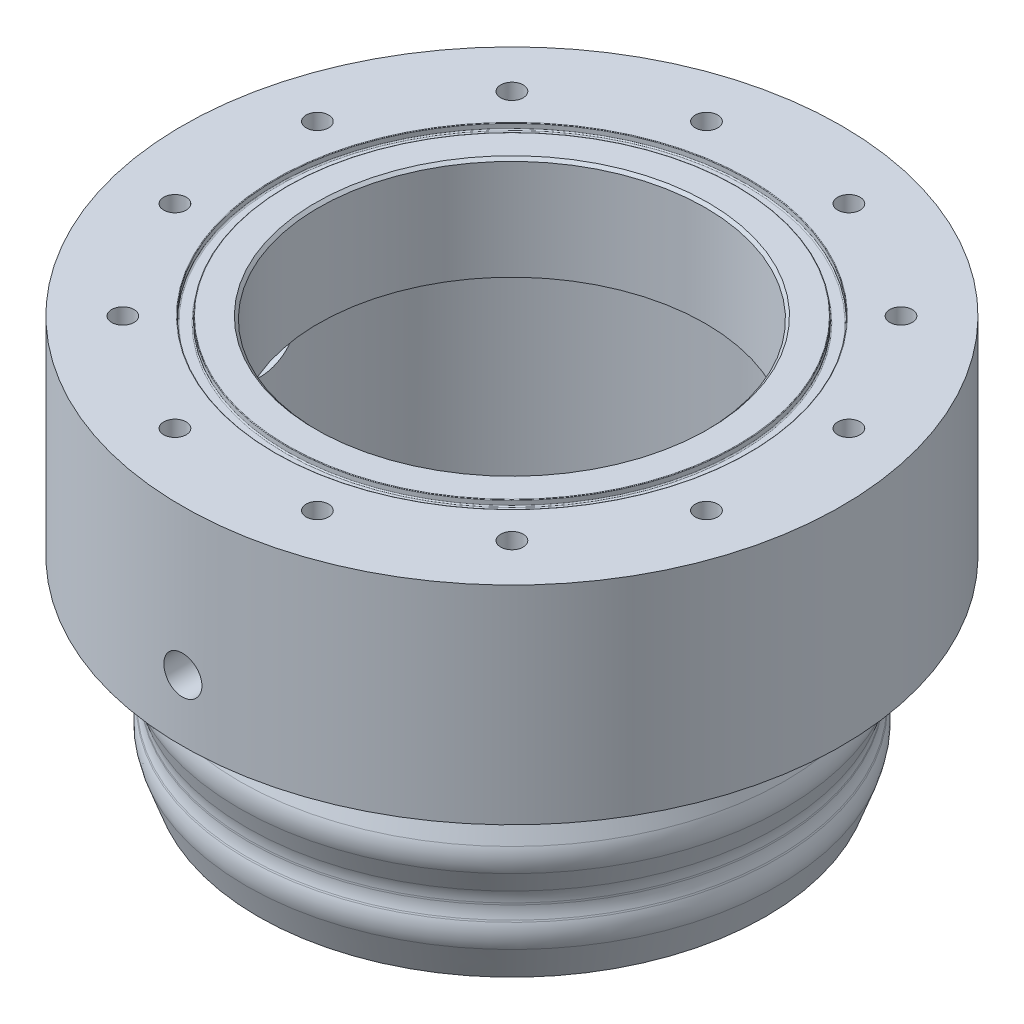
from build123d import *

# Parameters (mm, degrees)
ASSEMBLY_BOLT_INSERT_DIAMETER_R = 2.4892
ASSEMBLY_BOLT_INSERT_CUT_DEPTH  = 21.59
ASSEMBLY_BOLTS_COUNT            = 12
PT_CUT_DIAMETER_R               = 4.2164
PT_CUT_DEPTH                    = 158.465917682
FILLET1_R                       = 7.62
FILLET2_R                       = 2.54
FILLET3_R                       = 7.62
FILLET7_R                       = 7.62
SKETCH24_R                      = 7.14375
CUT_EXTRUDE2_DEPTH              = 25.4
CHAMFER1_SIZE                   = 0.635


with BuildPart() as part:
    # Flange profile → Flange (revolve)
    with BuildSketch(Plane.XY):
        with BuildLine():
            Line((-42.8625, 22.86), (-42.8625, 0))
            Line((-42.8625, 0), (-55.7276, 0))
            Line((-55.7276, 0), (-55.7276, -64.266896465))
            Line((-55.7276, -64.266896465), (-56.2356, -64.266896465))
            Line((-56.2356, -64.266896465), (-59.7916, -54.496866762))
            Line((-59.7916, -54.496866762), (-58.2676, -50.309711174))
            Line((-58.2676, -50.309711174), (-58.2676, -47.236311174))
            Line((-58.2676, -47.236311174), (-61.3156, -38.862))
            Line((-61.3156, -38.862), (-58.2676, -30.487688826))
            Line((-58.2676, -30.487688826), (-58.2676, -23.151254335))
            Line((-58.2676, -23.151254335), (-73.025, -23.151254335))
            Line((-73.025, -23.151254335), (-73.025, 22.86))
            Line((-73.025, 22.86), (-52.5653, 22.86))
            ThreePointArc((-52.5653, 22.86), (-52.475497439, 22.822802561), (-52.4383, 22.733))
            Line((-52.4383, 22.733), (-52.4383, 21.7932))
            ThreePointArc((-52.4383, 21.7932), (-52.363905122, 21.613594878), (-52.1843, 21.5392))
            Line((-52.1843, 21.5392), (-50.1269, 21.5392))
            ThreePointArc((-50.1269, 21.5392), (-49.947294878, 21.613594878), (-49.8729, 21.7932))
            Line((-49.8729, 21.7932), (-49.8729, 22.733))
            ThreePointArc((-49.8729, 22.733), (-49.835702561, 22.822802561), (-49.7459, 22.86))
            Line((-49.7459, 22.86), (-42.8625, 22.86))
        make_face()
    revolve(axis=Axis((0, 0, 0), (0, 1, 0)))

    # Assembly Bolt Insert Diameter → Assembly Bolt Insert Cut (cut)
    with BuildSketch(Plane(origin=(0, 22.86, 0), x_dir=(1, 0, 0), z_dir=(0, 1, 0))):
        with Locations((-58.882838371, 15.777608989)):
            Circle(ASSEMBLY_BOLT_INSERT_DIAMETER_R)
    assembly_bolt_insert_cut = extrude(amount=-ASSEMBLY_BOLT_INSERT_CUT_DEPTH, mode=Mode.SUBTRACT)

    # Assembly Bolts: Assembly Bolt Insert Cut ×12 about axis
    assembly_bolts_axis = Axis((0, 0, 0), (0, -1, 0))
    for i in range(1, ASSEMBLY_BOLTS_COUNT):
        add(assembly_bolt_insert_cut.rotate(assembly_bolts_axis, i * 360 / ASSEMBLY_BOLTS_COUNT), mode=Mode.SUBTRACT)

    # Pt Cut Diameter → Pt Cut (cut, through all)
    with BuildSketch(Plane.XY.offset(50.8)):
        with Locations((0, -9.525)):
            Circle(PT_CUT_DIAMETER_R)
    extrude(amount=PT_CUT_DEPTH, mode=Mode.SUBTRACT)

    # Fillet1
    fillet1_edges = [part.edges().sort_by_distance(p)[0] for p in [
        (61.3156, -38.862, 0),
    ]]
    fillet(fillet1_edges, radius=FILLET1_R)

    # Fillet2
    fillet2_edges = [part.edges().sort_by_distance(p)[0] for p in [
        (58.2676, -23.151254335, 0),
        (55.7276, 0, 0),
    ]]
    fillet(fillet2_edges, radius=FILLET2_R)

    # Fillet3
    fillet3_edges = [part.edges().sort_by_distance(p)[0] for p in [
        (59.7916, -54.496866762, 0),
    ]]
    fillet(fillet3_edges, radius=FILLET3_R)

    # Fillet7
    fillet7_edges = [part.edges().sort_by_distance(p)[0] for p in [
        (58.2676, -50.309711174, 0),
        (58.2676, -47.236311174, 0),
        (58.2676, -30.487688826, 0),
    ]]
    fillet(fillet7_edges, radius=FILLET7_R)

    # Sketch24 → Cut-Extrude2 (cut)
    with BuildSketch(Plane.ZY.offset(73.025)):
        with Locations((0, -9.525)):
            Circle(SKETCH24_R)
    extrude(amount=-CUT_EXTRUDE2_DEPTH, mode=Mode.SUBTRACT)

    # Chamfer1
    chamfer1_edges = [part.edges().sort_by_distance(p)[0] for p in [
        (42.8625, 22.86, 0),
    ]]
    chamfer(chamfer1_edges, length=CHAMFER1_SIZE)


solid = part.part
